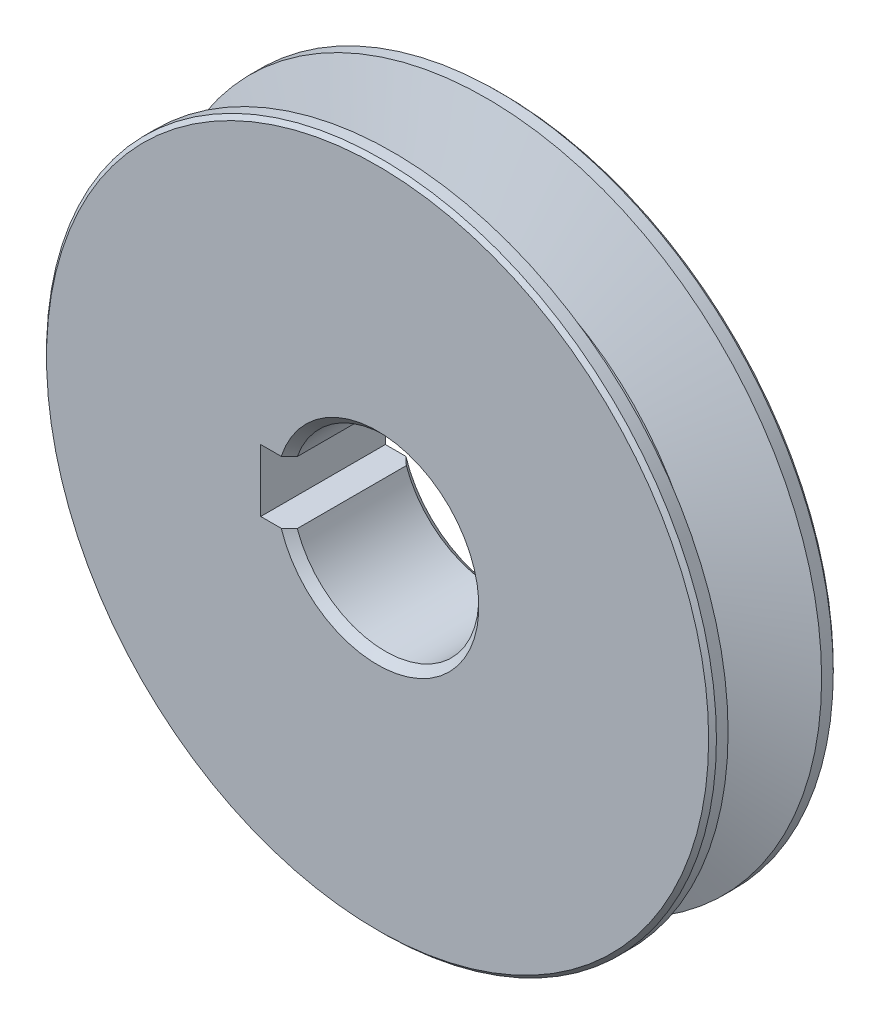
from build123d import *

# Parameters (mm, degrees)
CUT_EXTRUDE1_DEPTH = 17
SKETCH3_W          = 12
SKETCH3_H          = 16
CHAMFER1_SIZE2     = 1.000000021
CHAMFER1_SIZE      = 1.000000018
CHAMFER2_SIZE      = 0.5
SCALE1_SCALE       = 0.3


with BuildPart() as part:
    # Sketch1 → Revolve1 (revolve)
    with BuildSketch(Plane(origin=(0, 0, 0), x_dir=(1, 0, 0), z_dir=(0, 1, 0))):
        Polygon((43, 8), (0, 8), (0, -8), (43, -8), (43, -6.003672577), (32, -2), (32, 2), (43, 6.003672577), align=None)
    revolve(axis=Axis((0, 0, -8), (0, 0, 1)))

    # Sketch2 → Cut-Extrude1 (cut, through all)
    with BuildSketch(Plane.XY.offset(8)):
        with BuildLine():
            Line((-15, -4), (-11.313708499, -4))
            ThreePointArc((-11.313708499, -4), (-12, -1e-09), (-11.313708499, 3.999999999))
            Line((-11.313708499, 3.999999999), (-15, 3.999999999))
            Line((-15, 3.999999999), (-15, -4))
        make_face()
    extrude(amount=-CUT_EXTRUDE1_DEPTH, mode=Mode.SUBTRACT)

    # Sketch3 → Cut-Revolve1 (revolve, cut)
    with BuildSketch(Plane(origin=(0, 0, 0), x_dir=(1, 0, 0), z_dir=(0, 1, 0))):
        with Locations((6, 0)):
            Rectangle(SKETCH3_W, SKETCH3_H)
    revolve(axis=Axis((0, 0, -8), (0, 0, 1)), mode=Mode.SUBTRACT)

    # Chamfer1
    chamfer1_edges = [part.edges().sort_by_distance(p)[0] for p in [
        (12, 1e-09, -8),
        (12, 1e-09, 8),
    ]]
    chamfer(chamfer1_edges, length=CHAMFER1_SIZE, length2=CHAMFER1_SIZE2)

    # Chamfer2
    chamfer2_edges = [part.edges().sort_by_distance(p)[0] for p in [
        (-43, 0, 8),
        (-43, 0, -8),
    ]]
    chamfer(chamfer2_edges, length=CHAMFER2_SIZE)


with BuildPart() as part_1:
    # Scale1: scaled about (0.084922045, 0, 0)
    add(part.part.scale(SCALE1_SCALE).moved(Location((0.059445431, 0, 0))))


solid = part_1.part
